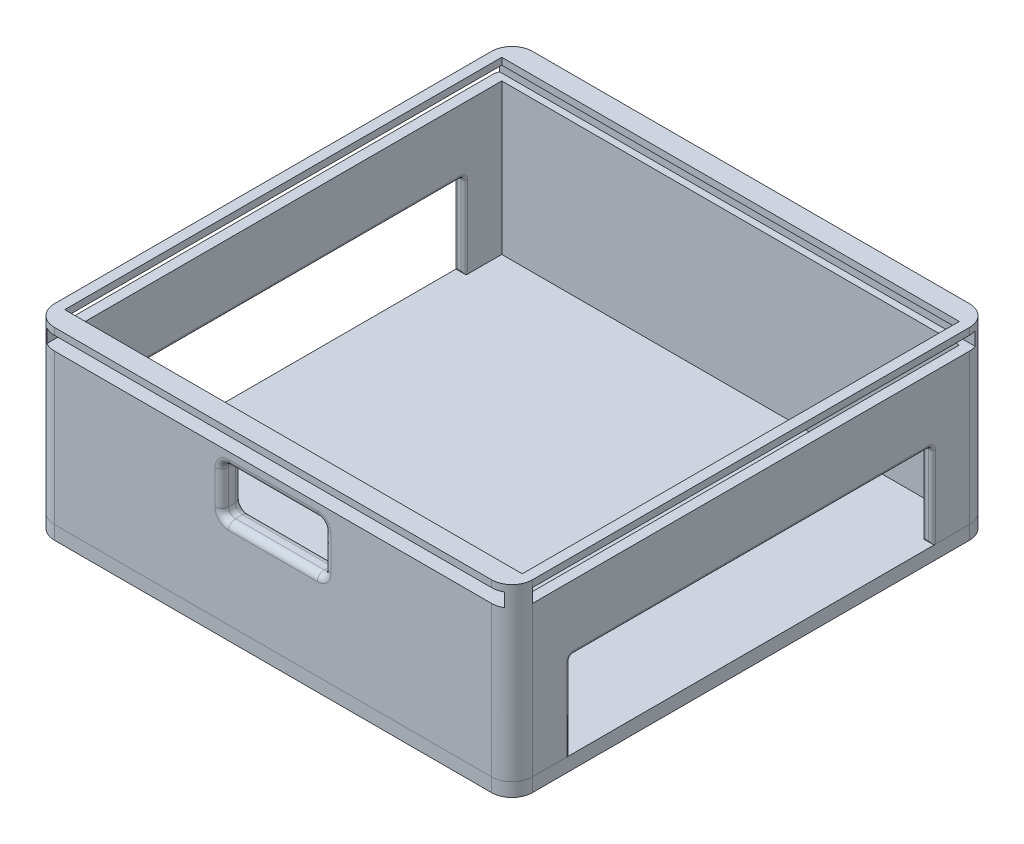
from build123d import *

# Parameters (mm, degrees)
CROQUIS1_W              = 70
CROQUIS1_H              = 70
CROQUIS1_W_2            = 67
CROQUIS1_H_2            = 64
SALIENTE_EXTRUIR2_DEPTH = 25
CROQUIS3_W              = 70
CROQUIS3_H              = 70
SALIENTE_EXTRUIR3_DEPTH = 2
CROQUIS4_W              = 53
CROQUIS4_H              = 12.5
CORTAR_EXTRUIR1_DEPTH   = 71
CROQUIS5_W              = 15
CROQUIS5_H              = 7
CORTAR_EXTRUIR2_DEPTH   = 3
REDONDEO2_R             = 3
REDONDEO4_R             = 1
CROQUIS6_W              = 67
CROQUIS6_H              = 2
CORTAR_EXTRUIR3_DEPTH   = 68
REDONDEO6_R             = 0.5
REDONDEO7_R             = 3
CROQUIS7_W              = 65
CROQUIS7_H              = 2
CORTAR_EXTRUIR4_DEPTH   = 71


with BuildPart() as part:
    # Croquis1 → Saliente-Extruir2 (new body)
    with BuildSketch(Plane(origin=(0, 0, 0), x_dir=(1, 0, 0), z_dir=(0, 1, 0))):
        Rectangle(CROQUIS1_W, CROQUIS1_H)
        Rectangle(CROQUIS1_W_2, CROQUIS1_H_2, mode=Mode.SUBTRACT)
    extrude(amount=SALIENTE_EXTRUIR2_DEPTH)

    # Croquis4 → Cortar-Extruir1 (cut, through all)
    with BuildSketch(Plane(origin=(35, 0, 0), x_dir=(0, 0, -1), z_dir=(1, 0, 0))):
        with Locations((0, 6.25)):
            Rectangle(CROQUIS4_W, CROQUIS4_H)
    extrude(amount=-CORTAR_EXTRUIR1_DEPTH, mode=Mode.SUBTRACT)

    # Croquis5 → Cortar-Extruir2 (cut)
    with BuildSketch(Plane.XY.offset(35)):
        with Locations((0, 16.5)):
            Rectangle(CROQUIS5_W, CROQUIS5_H)
    extrude(amount=-CORTAR_EXTRUIR2_DEPTH, mode=Mode.SUBTRACT)

    # Redondeo2
    redondeo2_edges = [part.edges().sort_by_distance(p)[0] for p in [
        (35, 12.5, 35),
        (-35, 12.5, 35),
        (-35, 12.5, -35),
        (35, 12.5, -35),
    ]]
    fillet(redondeo2_edges, radius=REDONDEO2_R)

    # Redondeo4
    redondeo4_edges = [part.edges().sort_by_distance(p)[0] for p in [
        (7.5, 16.5, 35),
        (0, 20, 35),
        (-7.5, 16.5, 35),
        (0, 13, 35),
        (0, 20, 32),
        (-7.5, 20, 33.5),
        (-7.5, 16.5, 32),
        (-7.5, 13, 33.5),
        (0, 13, 32),
        (7.5, 13, 33.5),
        (7.5, 16.5, 32),
        (7.5, 20, 33.5),
    ]]
    fillet(redondeo4_edges, radius=REDONDEO4_R)

    # Croquis6 → Cortar-Extruir3 (cut)
    with BuildSketch(Plane.XY.offset(35)):
        with Locations((0, 23)):
            Rectangle(CROQUIS6_W, CROQUIS6_H)
    extrude(amount=-CORTAR_EXTRUIR3_DEPTH, mode=Mode.SUBTRACT)

    # Redondeo6
    redondeo6_edges = [part.edges().sort_by_distance(p)[0] for p in [
        (-33.5, 12.5, 0),
        (-33.5, 6.25, 26.5),
        (-33.5, 6.25, -26.5),
        (33.5, 6.25, -26.5),
        (34.25, 12.5, -26.5),
        (34.25, 0, -26.5),
        (33.5, 6.25, 26.5),
        (34.25, 0, 26.5),
        (33.5, 12.5, 0),
        (34.25, 12.5, 26.5),
        (-35, 6.25, -26.5),
        (-34.25, 12.5, -26.5),
        (-34.25, 0, -26.5),
        (-35, 6.25, 26.5),
        (-34.25, 0, 26.5),
        (-35, 12.5, 0),
        (-34.25, 12.5, 26.5),
        (35, 6.25, -26.5),
        (35, 12.5, 0),
        (35, 6.25, 26.5),
    ]]
    fillet(redondeo6_edges, radius=REDONDEO6_R)

    # Croquis7 → Cortar-Extruir4 (cut, through all)
    with BuildSketch(Plane(origin=(35, 0, 0), x_dir=(0, 0, -1), z_dir=(1, 0, 0))):
        with Locations((0.5, 23)):
            Rectangle(CROQUIS7_W, CROQUIS7_H)
    extrude(amount=-CORTAR_EXTRUIR4_DEPTH, mode=Mode.SUBTRACT)


with BuildPart() as body_2:
    # Croquis3 → Saliente-Extruir3 (new body)
    with BuildSketch(Plane(origin=(0, 0, 0), x_dir=(1, 0, 0), z_dir=(0, 1, 0))):
        Rectangle(CROQUIS3_W, CROQUIS3_H)
    extrude(amount=-SALIENTE_EXTRUIR3_DEPTH)

    # Redondeo7
    redondeo7_edges = [body_2.edges().sort_by_distance(p)[0] for p in [
        (35, -1, 35),
        (-35, -1, 35),
        (-35, -1, -35),
        (35, -1, -35),
    ]]
    fillet(redondeo7_edges, radius=REDONDEO7_R)


solid = Compound([part.part, body_2.part])
